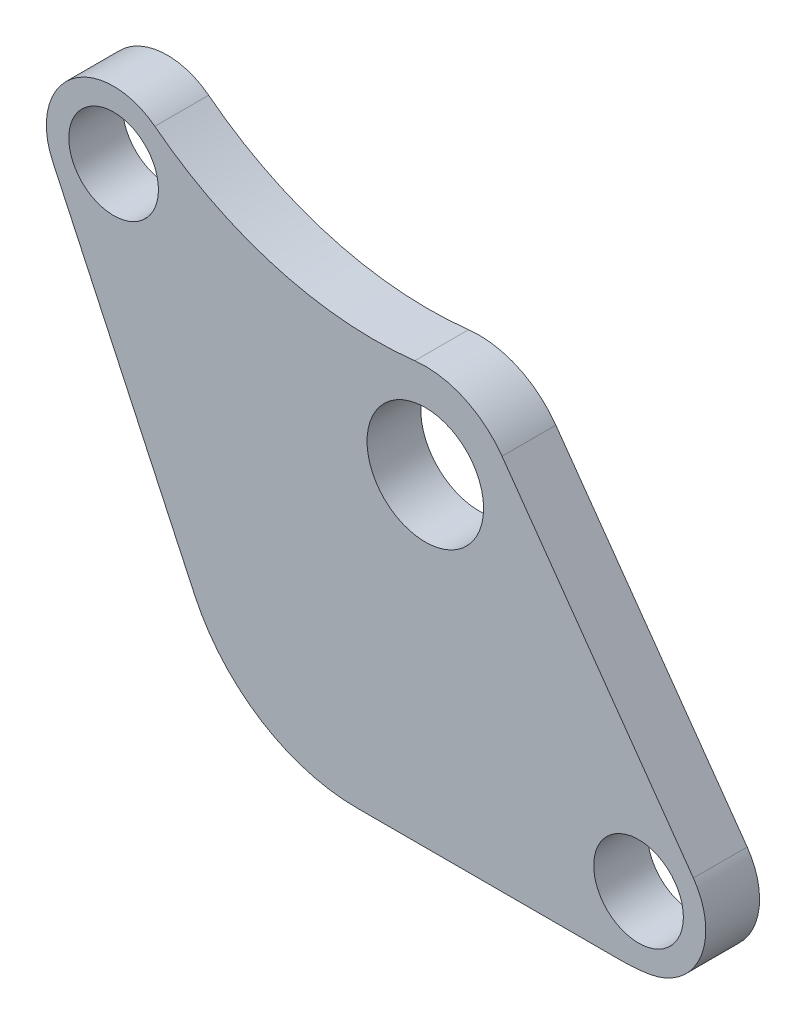
from build123d import *

# Parameters (mm, degrees)
SKETCH1_R           = 2.5
SKETCH1_R_2         = 3.25
BOSS_EXTRUDE1_DEPTH = 3
FILLET1_R           = 10


with BuildPart() as part:
    # Sketch1 → Boss-Extrude1 (new body)
    with BuildSketch(Plane.XY):
        with BuildLine():
            Line((-10.17794051, -18), (10.906121257, -18))
            ThreePointArc((10.906121257, -18), (11.696957788, -17.968679831), (12.482840492, -17.874915516))
            ThreePointArc((12.482840492, -17.874915516), (15.348919612, -15.624144149), (14.949938417, -12.001825103))
            Line((14.949938417, -12.001825103), (4.279753476, 3.036604394))
            ThreePointArc((4.279753476, 3.036604394), (2.143793972, 4.789718516), (-0.586612431, 5.214704394))
            ThreePointArc((-0.586612431, 5.214704394), (-8.234060053, 5.835429339), (-15.085056175, 9.289789878))
            ThreePointArc((-15.085056175, 9.289789878), (-19.723438647, 9.258412309), (-20.782967686, 4.74255417))
            Line((-20.782967686, 4.74255417), (-10.17794051, -18))
        make_face()
        with Locations((-17.384313485, 6.327372652)):
            Circle(SKETCH1_R, mode=Mode.SUBTRACT)
        with Locations((11.891570779, -14.171822198)):
            Circle(SKETCH1_R, mode=Mode.SUBTRACT)
        Circle(SKETCH1_R_2, mode=Mode.SUBTRACT)
    extrude(amount=BOSS_EXTRUDE1_DEPTH)

    # Fillet1
    fillet1_edges = [part.edges().sort_by_distance(p)[0] for p in [
        (-10.17794051, -18, 1.5),
    ]]
    fillet(fillet1_edges, radius=FILLET1_R)


solid = part.part
